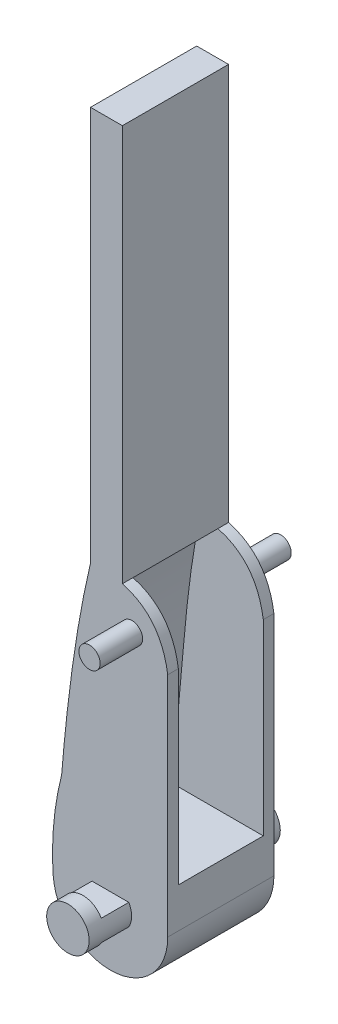
from build123d import *

# Parameters (mm, degrees)
EXTRUDE_1_DEPTH          = 5
SKETCH_3_R               = 2
SKETCH_3_R_2             = 1
EXTRUDE_2_DEPTH          = 4
EXTRUDE_2_DEPTH_BACK     = 14
CUT_EXTRUDE_1_DEPTH      = 4
SKETCH_4_W               = 2.59101906
SKETCH_4_H               = 1.951015164
SKETCH_4_H_2             = 2.185859581
CUT_EXTRUDE_2_DEPTH      = 1
CUT_EXTRUDE_2_DEPTH_BACK = 22.850089698
SKETCH_5_W               = 31.280846128
SKETCH_5_H               = 26.509191634
CUT_EXTRUDE_3_DEPTH      = 10
CUT_EXTRUDE_4_DEPTH      = 10
EXTRUDE_4_DEPTH          = 10


with BuildPart() as part:
    # 草图1 → 凸台-拉伸1 (new body, symmetric)
    with BuildSketch(Plane.XY):
        with BuildLine():
            Line((-11, -0.656322646), (-11, -22.429975294))
            ThreePointArc((-11, -22.429975294), (-16.212842401, -27.826367541), (-21.786325372, -22.803314409))
            add(Edge.make_bspline(
                [(-20.992129713, -14.197793305), (-22.083985192, -18.508547069), (-21.786325372, -22.803314409)],
                knots=[0, 0, 0, 0.849528989, 0.849528989, 0.849528989], degree=2))
            add(Edge.make_bspline(
                [(-20.992129713, -14.197793305), (-19.982477614, -1.835246339), (-16.911295032, 22.315403308), (-5.101083491, 23.268557164)],
                knots=[0.325260196, 0.325260196, 0.325260196, 0.325260196, 1, 1, 1, 1], degree=3))
            Line((-5.101083491, 23.268557164), (-5.101083491, 16.3035208))
            ThreePointArc((-5.101083491, 16.3035208), (-5.344239377, 14.111719499), (-6.061882079, 12.026508076))
            Line((-6.061882079, 12.026508076), (-10.039201412, 3.620690077))
            ThreePointArc((-10.039201412, 3.620690077), (-10.756844114, 1.535478654), (-11, -0.656322646))
        make_face()
    extrude(amount=EXTRUDE_1_DEPTH, both=True)

    # 草图3 → 凸台-拉伸2 (add, two sides)
    with BuildSketch(Plane.XY.offset(5)) as extrude_2_sk:
        with Locations((-16.399623741, -22.429975294)):
            Circle(SKETCH_3_R)
        with Locations((-14.366531857, 0.706079338)):
            Circle(SKETCH_3_R_2)
    extrude(amount=EXTRUDE_2_DEPTH)
    extrude(extrude_2_sk.sketch, amount=-EXTRUDE_2_DEPTH_BACK)

    # 草图2 → 切除-拉伸1 (cut, symmetric)
    with BuildSketch(Plane.XY):
        with BuildLine():
            Line((-14.16063588, 12.808117781), (14.16063588, 12.808117781))
            add(Edge.make_bspline(
                [(14.16063588, 12.808117781), (18.7957473, 3.012389753), (18.151937314, -8.213759494), (19.7286529, -18.675237718)],
                knots=[0, 0, 0, 0, 1, 1, 1, 1], degree=3))
            Line((19.7286529, -18.675237718), (-19.7286529, -18.675237718))
            add(Edge.make_bspline(
                [(-14.16063588, 12.808117781), (-18.7957473, 3.012389753), (-18.151937314, -8.213759494), (-19.7286529, -18.675237718)],
                knots=[0, 0, 0, 0, 1, 1, 1, 1], degree=3))
        make_face()
    extrude(amount=CUT_EXTRUDE_1_DEPTH, both=True, mode=Mode.SUBTRACT)

    # 草图4 → 切除-拉伸2 (cut, two sides)
    with BuildSketch(Plane(origin=(0, 0, 0), x_dir=(0, 0, -1), z_dir=(1, 0, 0))) as cut_extrude_2_sk:
        with Locations((-6.29550953, -20.454467712)):
            Rectangle(SKETCH_4_W, SKETCH_4_H)
        with Locations((-6.29550953, -24.522905085)):
            Rectangle(SKETCH_4_W, SKETCH_4_H_2)
        with Locations((6.29550953, -24.522905085)):
            Rectangle(SKETCH_4_W, SKETCH_4_H_2)
        with Locations((6.29550953, -20.454467712)):
            Rectangle(SKETCH_4_W, SKETCH_4_H)
    extrude(amount=CUT_EXTRUDE_2_DEPTH, mode=Mode.SUBTRACT)
    extrude(cut_extrude_2_sk.sketch, amount=-CUT_EXTRUDE_2_DEPTH_BACK, mode=Mode.SUBTRACT)

    # 草图5 → 切除-拉伸3 (cut)
    with BuildSketch(Plane.XY.offset(5)):
        with Locations((-12.035980348, 17.707965105)):
            Rectangle(SKETCH_5_W, SKETCH_5_H)
    extrude(amount=-CUT_EXTRUDE_3_DEPTH, mode=Mode.SUBTRACT)

    # 草图6 → 切除-拉伸4 (cut)
    with BuildSketch(Plane.XY.offset(5)):
        with BuildLine():
            Line((-11, -1.030772695), (-7.289425252, 0))
            Line((-7.289425252, 0), (-6.627618858, 7.054774986))
            Line((-6.627618858, 7.054774986), (-15.000908449, 5.846258962))
            Line((-15.000908449, 5.846258962), (-16.238198664, 4.453369288))
            add(Edge.make_bspline(
                [(-16.238198664, 4.453369288), (-11.717955923, 3.797110984), (-11, -1.030772695)],
                knots=[0, 0, 0, 1, 1, 1], degree=2))
        make_face()
    extrude(amount=-CUT_EXTRUDE_4_DEPTH, mode=Mode.SUBTRACT)

    # 草图7 → 凸台-拉伸4 (add)
    with BuildSketch(Plane.XY.offset(5)):
        Polygon((-18.271249604, 4.453369288), (-18.271249604, 41.616361527), (-15.271249597, 41.616361527), (-15.271249604, 4.25345908), align=None)
    extrude(amount=-EXTRUDE_4_DEPTH)


solid = part.part
